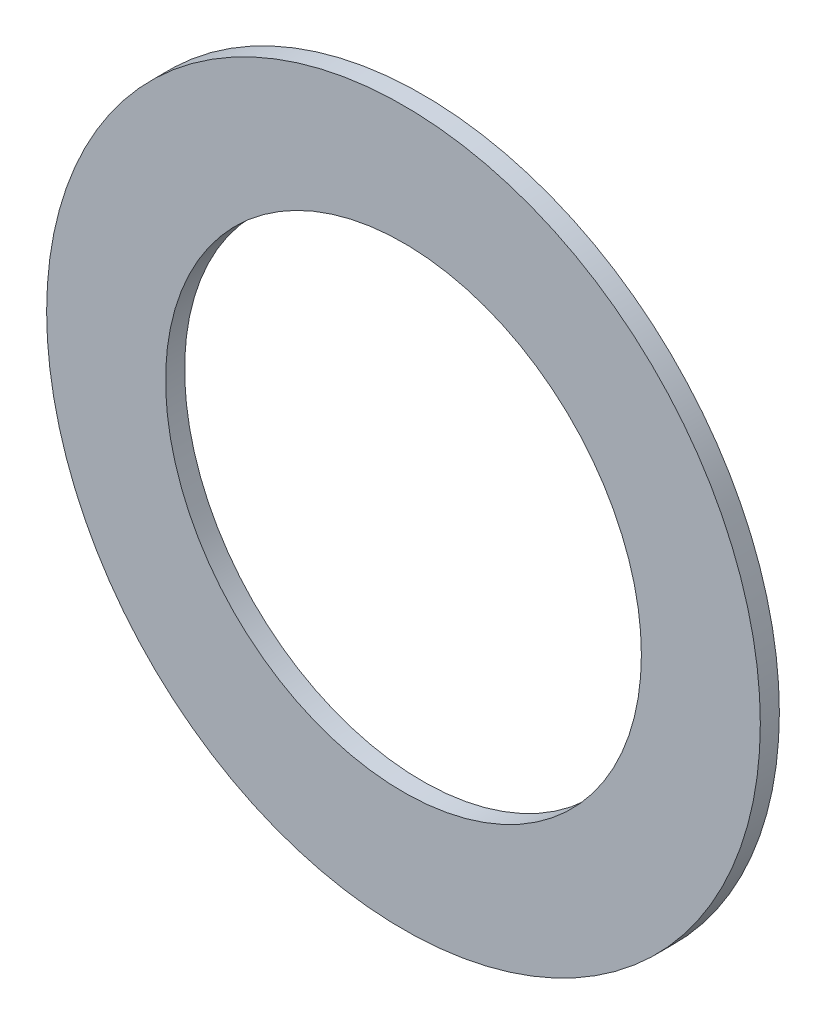
from build123d import *

# Parameters (mm, degrees)
SKETCH1_R      = 4.7625
SKETCH1_R_2    = 3.175
EXTRUDE1_DEPTH = 0.254


with BuildPart() as part:
    # Sketch1 → Extrude1 (new body)
    with BuildSketch(Plane.XY):
        Circle(SKETCH1_R)
        Circle(SKETCH1_R_2, mode=Mode.SUBTRACT)
    extrude(amount=EXTRUDE1_DEPTH)


solid = part.part
